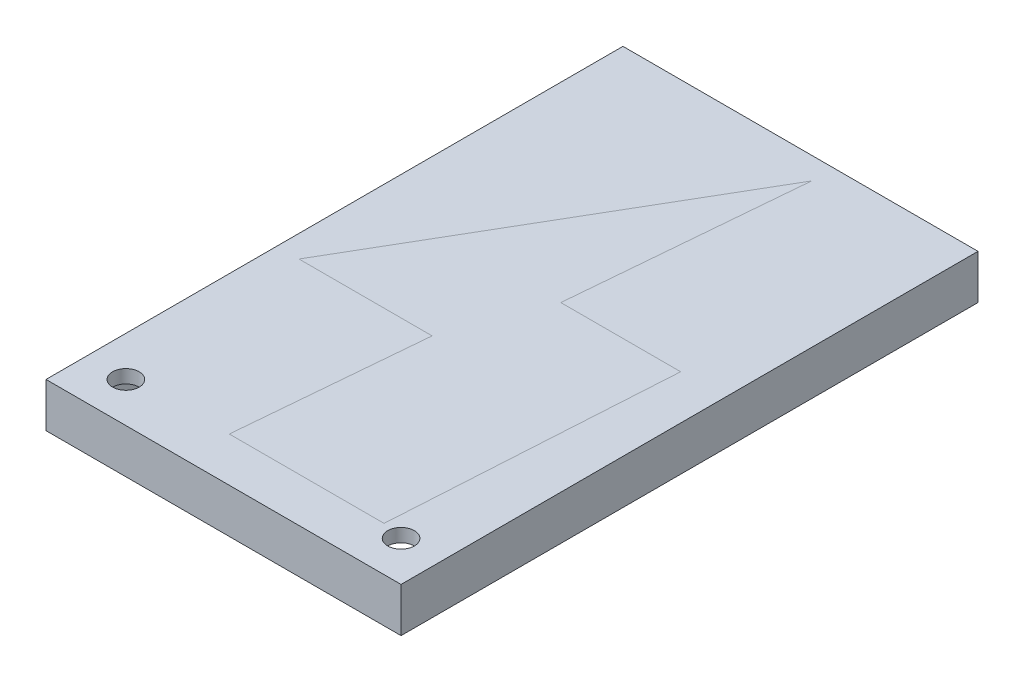
from build123d import *

# Parameters (mm, degrees)
SKETCH1_W                    = 80
SKETCH1_H                    = 130
BOSS_EXTRUDE1_DEPTH          = 10
SKETCH2_W                    = 70
SKETCH2_H                    = 120
CUT_EXTRUDE1_DEPTH           = 7
CUT_EXTRUDE2_DEPTH           = 11
DRAFT1_ANGLE                 = -5.033852659
DRAFT2_ANGLE                 = 3.479843222
F_6_0_6_DIAMETER_HOLE1_D     = 6
F_6_0_6_DIAMETER_HOLE1_DEPTH = 10
BOSS_EXTRUDE2_DEPTH          = 1


with BuildPart() as part:
    # Sketch1 → Boss-Extrude1 (new body)
    with BuildSketch(Plane.XZ.offset(7)):
        with Locations((-35, 60)):
            Rectangle(SKETCH1_W, SKETCH1_H)
    extrude(amount=-BOSS_EXTRUDE1_DEPTH)

    # Sketch2 → Cut-Extrude1 (cut)
    with BuildSketch(Plane.XZ.offset(7)):
        with Locations((-35, 60)):
            Rectangle(SKETCH2_W, SKETCH2_H)
    extrude(amount=-CUT_EXTRUDE1_DEPTH, mode=Mode.SUBTRACT)

    # Sketch3 → Cut-Extrude2 (cut, through all)
    with BuildSketch(Plane(origin=(0, 3, 0), x_dir=(-1, 0, 0), z_dir=(0, 1, 0))):
        Polygon((40, 115), (8.830999101, 115), (8.830999101, 52), (32, 52), (27.476443014, 0), (70, 73), (40, 73), align=None)
    extrude(amount=-CUT_EXTRUDE2_DEPTH, mode=Mode.SUBTRACT)

    # Draft1
    draft1_faces = [part.faces().sort_by_distance(p)[0] for p in [
        (-40, 1.5, 94),
    ]]
    draft(draft1_faces, Plane(origin=(-70, -7, 73), x_dir=(-1, 0, 0), z_dir=(0, 0, -1)), DRAFT1_ANGLE)

    # Draft2
    draft2_faces = [part.faces().sort_by_distance(p)[0] for p in [
        (-8.830999101, 1.5, 83.5),
    ]]
    draft(draft2_faces, Plane(origin=(-40, -7, 115), x_dir=(-1, 0, 0), z_dir=(0, 0, -1)), DRAFT2_ANGLE)

    # Ø6.0 (6) Diameter Hole1
    with Locations(Plane(origin=(0, 3, 0), x_dir=(1, 0, 0), z_dir=(0, 1, 0))):
        with Locations((-66, -116), (-4, -116)):
            Hole(F_6_0_6_DIAMETER_HOLE1_D / 2, depth=F_6_0_6_DIAMETER_HOLE1_DEPTH)


with BuildPart() as body_2:
    # Sketch6 → Boss-Extrude2 (new body)
    with BuildSketch(Plane(origin=(0, 3, 0), x_dir=(1, 0, 0), z_dir=(0, 1, 0))):
        Polygon((-5, -52), (-32, -52), (-27.476443014, 0), (-70, -73), (-40, -73), (-43.699530401, -115), (-8.830999101, -115), align=None)
    extrude(amount=-BOSS_EXTRUDE2_DEPTH)


solid = Compound([part.part, body_2.part])
